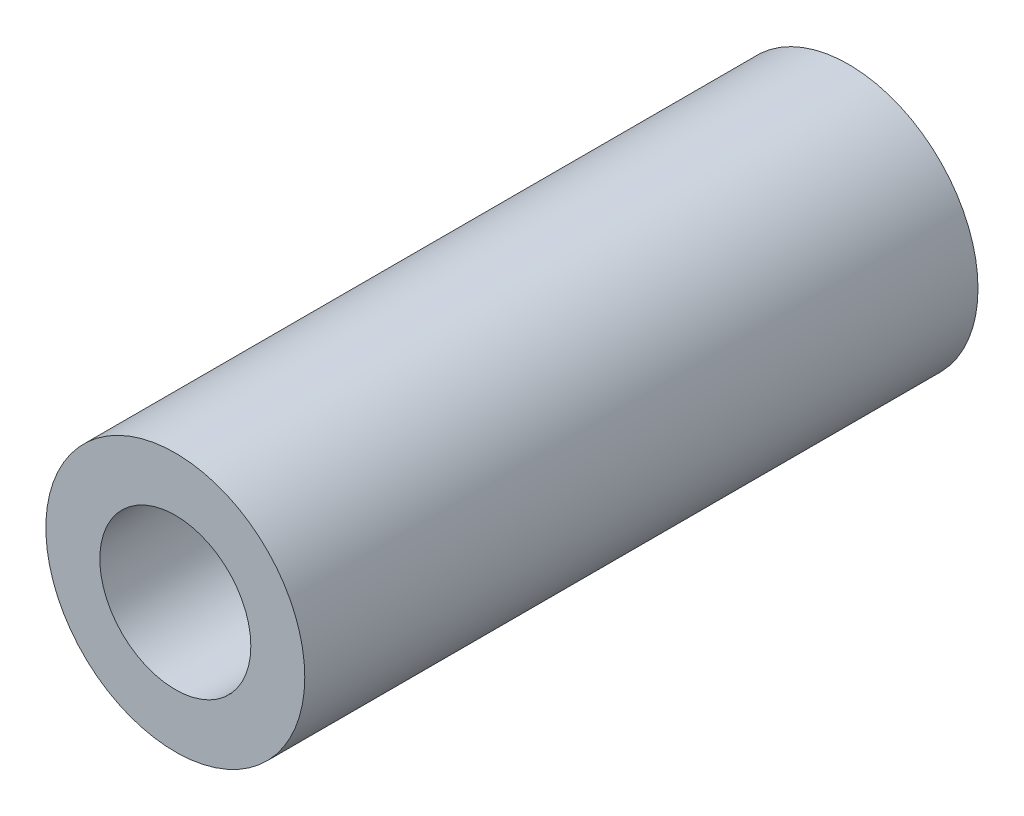
from build123d import *

# Parameters (mm, degrees)
SKETCH_1_R      = 6
SKETCH_1_R_2    = 3.5
EXTRUDE_1_DEPTH = 15.6


with BuildPart() as part:
    # 草图1 → 凸台-拉伸1 (new body, symmetric)
    with BuildSketch(Plane.XY):
        Circle(SKETCH_1_R)
        Circle(SKETCH_1_R_2, mode=Mode.SUBTRACT)
    extrude(amount=EXTRUDE_1_DEPTH, both=True)


solid = part.part
